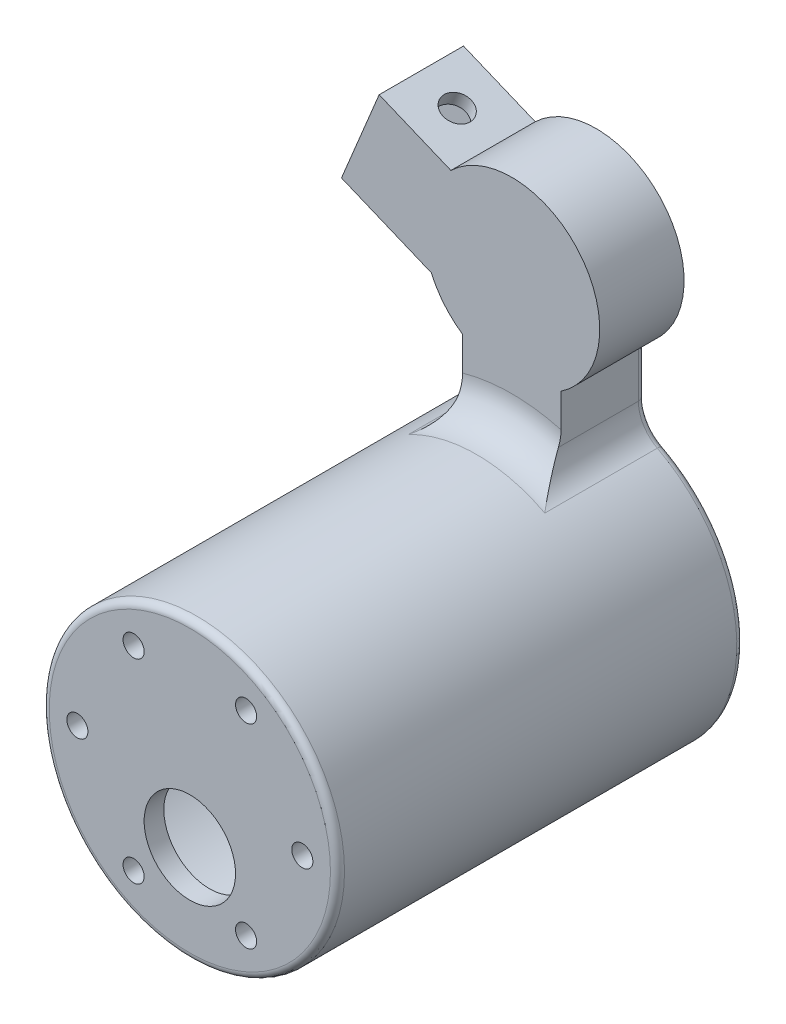
from build123d import *

# Parameters (mm, degrees)
SKETCH1_R           = 12.5
BOSS_EXTRUDE2_DEPTH = 12
BOSS_EXTRUDE3_DEPTH = 12
SKETCH5_R           = 21.000952359
BOSS_EXTRUDE4_DEPTH = 57.8
SKETCH6_R           = 19
CUT_EXTRUDE3_DEPTH  = 55
SKETCH7_R           = 6.5
SKETCH7_R_2         = 1.5
CUT_EXTRUDE4_DEPTH  = 58.8
FILLET1_R           = 5
FILLET2_R           = 1
SKETCH8_W           = 8
SKETCH8_H           = 10
CUT_EXTRUDE5_DEPTH  = 10
SKETCH9_R           = 2
CUT_EXTRUDE6_DEPTH  = 71.774772921


with BuildPart() as part:
    # Sketch1 → Boss-Extrude2 (new body)
    with BuildSketch(Plane.XY):
        Circle(SKETCH1_R)
    extrude(amount=BOSS_EXTRUDE2_DEPTH)

    # Sketch2 → Boss-Extrude3 (add)
    with BuildSketch(Plane.XY):
        with BuildLine():
            Line((7, -10.356157589), (7, -20.356157589))
            Line((7, -20.356157589), (-7, -20.356157589))
            Line((-7, -20.356157589), (-7, -10.356157589))
            ThreePointArc((-7, -10.356157589), (0, -12.5), (7, -10.356157589))
        make_face()
        with BuildLine():
            Line((-24.231440373, 0.295461436), (-11.458506302, -4.995261088))
            ThreePointArc((-11.458506302, -4.995261088), (-12.259311424, 2.441164357), (-8.670952565, 9.003587153))
            Line((-8.670952565, 9.003587153), (-18.87387232, 13.229774891))
            Line((-18.87387232, 13.229774891), (-20.787289482, 8.610377228))
            Line((-20.787289482, 8.610377228), (-24.231440373, 0.295461436))
        make_face()
    extrude(amount=BOSS_EXTRUDE3_DEPTH)

    # Sketch5 → Boss-Extrude4 (add)
    with BuildSketch(Plane.XY):
        with Locations((0, -40.156157589)):
            Circle(SKETCH5_R)
    extrude(amount=BOSS_EXTRUDE4_DEPTH)

    # Sketch6 → Cut-Extrude3 (cut)
    with BuildSketch(Plane(origin=(0, 0, 0), x_dir=(-1, 0, 0), z_dir=(0, 0, -1))):
        with Locations((0, -40.156157589)):
            Circle(SKETCH6_R)
    extrude(amount=-CUT_EXTRUDE3_DEPTH, mode=Mode.SUBTRACT)

    # Sketch7 → Cut-Extrude4 (cut, through all)
    with BuildSketch(Plane.XY.offset(57.8)):
        with Locations((0, -47.156157589)):
            Circle(SKETCH7_R)
        with Locations((-16, -40.156157589)):
            Circle(SKETCH7_R_2)
        with Locations((-8, -54.012564049)):
            Circle(SKETCH7_R_2)
        with Locations((8, -54.012564049)):
            Circle(SKETCH7_R_2)
        with Locations((16, -40.156157589)):
            Circle(SKETCH7_R_2)
        with Locations((8, -26.299751128)):
            Circle(SKETCH7_R_2)
        with Locations((-8, -26.299751128)):
            Circle(SKETCH7_R_2)
    extrude(amount=-CUT_EXTRUDE4_DEPTH, mode=Mode.SUBTRACT)

    # Fillet1
    fillet1_edges = [part.edges().sort_by_distance(p)[0] for p in [
        (0, -19.155205229, 12),
        (-7, -20.356157589, 6),
        (7, -20.356157589, 6),
    ]]
    fillet(fillet1_edges, radius=FILLET1_R)

    # Fillet2
    fillet2_edges = [part.edges().sort_by_distance(p)[0] for p in [
        (-21.000952359, -40.156157589, 57.8),
        (19, -40.156157589, 0),
        (-7, -13.723058226, 0),
        (7, -13.723058226, 0),
        (-10.897030164, -58.108726586, 0),
        (7.725772648, -19.684372198, 0),
        (-7.725772648, -19.684372198, 0),
    ]]
    fillet(fillet2_edges, radius=FILLET2_R)

    # Sketch8 → Cut-Extrude5 (cut)
    with BuildSketch(Plane(origin=(-20.787289482, 8.610377228, 0), x_dir=(0, 0, 1), z_dir=(-0.923879533, 0.382683432, 0))):
        with Locations((6, -2)):
            Rectangle(SKETCH8_W, SKETCH8_H)
    extrude(amount=-CUT_EXTRUDE5_DEPTH, mode=Mode.SUBTRACT)

    # Sketch9 → Cut-Extrude6 (cut, through all)
    with BuildSketch(Plane(origin=(1.913417162, 4.619397663, 0), x_dir=(0.923879533, -0.382683432, 0), z_dir=(0.382683432, 0.923879533, 0))):
        with Locations((-16.978219619, -6)):
            Circle(SKETCH9_R)
    extrude(amount=-CUT_EXTRUDE6_DEPTH, mode=Mode.SUBTRACT)


solid = part.part
